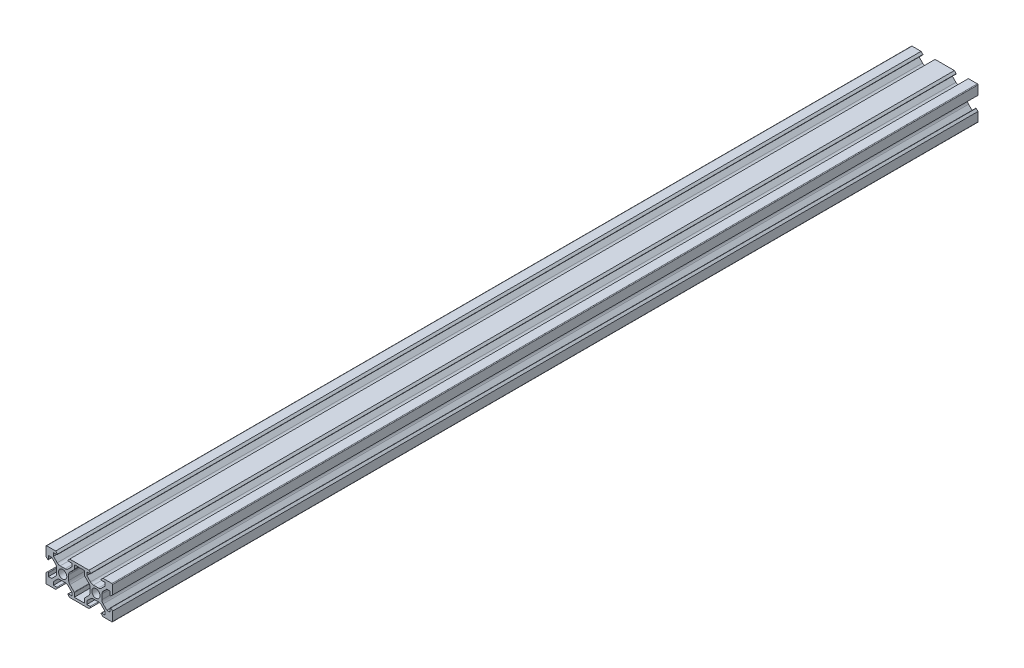
from build123d import *

# Parameters (mm, degrees)
RESSALTO_EXTRUS_O1_DEPTH = 260


with BuildPart() as part:
    # Esboço1 → Ressalto-extrusão1 (new body, symmetric)
    with BuildSketch(Plane.XY):
        with BuildLine():
            Line((-13.1, 8.9), (-14.2, 10))
            Line((-14.2, 10), (-19.6, 10))
            ThreePointArc((-19.6, 10), (-19.882842712, 9.882842712), (-20, 9.6))
            Line((-20, 9.6), (-20, 4.2))
            Line((-20, 4.2), (-18.9, 3.1))
            ThreePointArc((-18.9, 3.1), (-18.617157287, 3.217157287), (-18.5, 3.5))
            Line((-18.5, 3.5), (-18.5, 5.5))
            Line((-18.5, 5.5), (-16.560660172, 5.5))
            Line((-16.560660172, 5.5), (-14.332233047, 3.271572875))
            ThreePointArc((-14.332233047, 3.271572875), (-13.790301169, 2.460514503), (-13.6, 1.503805922))
            Line((-13.6, 1.503805922), (-13.6, 0))
            Line((-13.6, 0), (-13.6, -1.503805922))
            ThreePointArc((-13.6, -1.503805922), (-13.790301169, -2.460514503), (-14.332233047, -3.271572875))
            Line((-14.332233047, -3.271572875), (-16.560660172, -5.5))
            Line((-16.560660172, -5.5), (-18.5, -5.5))
            Line((-18.5, -5.5), (-18.5, -3.5))
            ThreePointArc((-18.5, -3.5), (-18.617157287, -3.217157288), (-18.9, -3.1))
            Line((-18.9, -3.1), (-20, -4.2))
            Line((-20, -4.2), (-20, -9.6))
            ThreePointArc((-20, -9.6), (-19.882842712, -9.882842712), (-19.6, -10))
            Line((-19.6, -10), (-14.2, -10))
            Line((-14.2, -10), (-13.1, -8.9))
            ThreePointArc((-13.1, -8.9), (-13.217157287, -8.617157288), (-13.5, -8.5))
            Line((-13.5, -8.5), (-15.5, -8.5))
            Line((-15.5, -8.5), (-15.5, -6.560660172))
            Line((-15.5, -6.560660172), (-13.271572875, -4.332233047))
            ThreePointArc((-13.271572875, -4.332233047), (-12.460514503, -3.790301169), (-11.503805922, -3.6))
            Line((-11.503805922, -3.6), (-10, -3.6))
            Line((-10, -3.6), (-8.496194078, -3.6))
            ThreePointArc((-8.496194078, -3.6), (-7.539485497, -3.790301169), (-6.728427125, -4.332233047))
            Line((-6.728427125, -4.332233047), (-4.5, -6.560660172))
            Line((-4.5, -6.560660172), (-4.5, -8.5))
            Line((-4.5, -8.5), (-6.5, -8.5))
            ThreePointArc((-6.5, -8.5), (-6.782842712, -8.617157288), (-6.9, -8.9))
            Line((-6.9, -8.9), (-5.8, -10))
            Line((-5.8, -10), (5.8, -10))
            Line((5.8, -10), (6.9, -8.9))
            ThreePointArc((6.9, -8.9), (6.782842712, -8.617157288), (6.5, -8.5))
            Line((6.5, -8.5), (4.5, -8.5))
            Line((4.5, -8.5), (4.5, -6.560660172))
            Line((4.5, -6.560660172), (6.728427125, -4.332233047))
            ThreePointArc((6.728427125, -4.332233047), (7.539485497, -3.790301169), (8.496194078, -3.6))
            Line((8.496194078, -3.6), (10, -3.6))
            Line((10, -3.6), (11.503805922, -3.6))
            ThreePointArc((11.503805922, -3.6), (12.460514503, -3.790301169), (13.271572875, -4.332233047))
            Line((13.271572875, -4.332233047), (15.5, -6.560660172))
            Line((15.5, -6.560660172), (15.5, -8.5))
            Line((15.5, -8.5), (13.5, -8.5))
            ThreePointArc((13.5, -8.5), (13.217157287, -8.617157288), (13.1, -8.9))
            Line((13.1, -8.9), (14.2, -10))
            Line((14.2, -10), (19.6, -10))
            ThreePointArc((19.6, -10), (19.882842712, -9.882842712), (20, -9.6))
            Line((20, -9.6), (20, -4.2))
            Line((20, -4.2), (18.9, -3.1))
            ThreePointArc((18.9, -3.1), (18.617157287, -3.217157288), (18.5, -3.5))
            Line((18.5, -3.5), (18.5, -5.5))
            Line((18.5, -5.5), (16.560660172, -5.5))
            Line((16.560660172, -5.5), (14.332233047, -3.271572875))
            ThreePointArc((14.332233047, -3.271572875), (13.790301169, -2.460514503), (13.6, -1.503805922))
            Line((13.6, -1.503805922), (13.6, 0))
            Line((13.6, 0), (13.6, 1.503805922))
            ThreePointArc((13.6, 1.503805922), (13.790301169, 2.460514503), (14.332233047, 3.271572875))
            Line((14.332233047, 3.271572875), (16.560660172, 5.5))
            Line((16.560660172, 5.5), (18.5, 5.5))
            Line((18.5, 5.5), (18.5, 3.5))
            ThreePointArc((18.5, 3.5), (18.617157287, 3.217157287), (18.9, 3.1))
            Line((18.9, 3.1), (20, 4.2))
            Line((20, 4.2), (20, 9.6))
            ThreePointArc((20, 9.6), (19.882842712, 9.882842712), (19.6, 10))
            Line((19.6, 10), (14.2, 10))
            Line((14.2, 10), (13.1, 8.9))
            ThreePointArc((13.1, 8.9), (13.217157287, 8.617157287), (13.5, 8.5))
            Line((13.5, 8.5), (15.5, 8.5))
            Line((15.5, 8.5), (15.5, 6.560660172))
            Line((15.5, 6.560660172), (13.271572875, 4.332233047))
            ThreePointArc((13.271572875, 4.332233047), (12.460514503, 3.790301169), (11.503805922, 3.6))
            Line((11.503805922, 3.6), (10, 3.6))
            Line((10, 3.6), (8.496194078, 3.6))
            ThreePointArc((8.496194078, 3.6), (7.539485497, 3.790301169), (6.728427125, 4.332233047))
            Line((6.728427125, 4.332233047), (4.5, 6.560660172))
            Line((4.5, 6.560660172), (4.5, 8.5))
            Line((4.5, 8.5), (6.5, 8.5))
            ThreePointArc((6.5, 8.5), (6.782842712, 8.617157288), (6.9, 8.9))
            Line((6.9, 8.9), (5.8, 10))
            Line((5.8, 10), (-5.8, 10))
            Line((-5.8, 10), (-6.9, 8.9))
            ThreePointArc((-6.9, 8.9), (-6.782842712, 8.617157288), (-6.5, 8.5))
            Line((-6.5, 8.5), (-4.5, 8.5))
            Line((-4.5, 8.5), (-4.5, 6.560660172))
            Line((-4.5, 6.560660172), (-6.728427125, 4.332233047))
            ThreePointArc((-6.728427125, 4.332233047), (-7.539485497, 3.790301169), (-8.496194078, 3.6))
            Line((-8.496194078, 3.6), (-10, 3.6))
            Line((-10, 3.6), (-11.503805922, 3.6))
            ThreePointArc((-11.503805922, 3.6), (-12.460514503, 3.790301169), (-13.271572875, 4.332233047))
            Line((-13.271572875, 4.332233047), (-15.5, 6.560660172))
            Line((-15.5, 6.560660172), (-15.5, 8.5))
            Line((-15.5, 8.5), (-13.5, 8.5))
            ThreePointArc((-13.5, 8.5), (-13.217157287, 8.617157287), (-13.1, 8.9))
        make_face()
        with BuildLine():
            Line((-3, 8.5), (3, 8.5))
            Line((3, 8.5), (3, 6.105025253))
            ThreePointArc((3, 6.105025253), (3.030448187, 5.95195188), (3.117157288, 5.822182541))
            Line((3.117157288, 5.822182541), (5.667766953, 3.271572875))
            ThreePointArc((5.667766953, 3.271572875), (6.209698831, 2.460514503), (6.4, 1.503805922))
            Line((6.4, 1.503805922), (6.4, 0))
            Line((6.4, 0), (6.4, -1.503805922))
            ThreePointArc((6.4, -1.503805922), (6.209698831, -2.460514503), (5.667766953, -3.271572875))
            Line((5.667766953, -3.271572875), (3.117157288, -5.822182541))
            ThreePointArc((3.117157288, -5.822182541), (3.030448187, -5.95195188), (3, -6.105025253))
            Line((3, -6.105025253), (3, -8.5))
            Line((3, -8.5), (-3, -8.5))
            Line((-3, -8.5), (-3, -6.105025253))
            ThreePointArc((-3, -6.105025253), (-3.030448187, -5.95195188), (-3.117157288, -5.822182541))
            Line((-3.117157288, -5.822182541), (-5.667766953, -3.271572875))
            ThreePointArc((-5.667766953, -3.271572875), (-6.209698831, -2.460514503), (-6.4, -1.503805922))
            Line((-6.4, -1.503805922), (-6.4, 0))
            Line((-6.4, 0), (-6.4, 1.503805922))
            ThreePointArc((-6.4, 1.503805922), (-6.209698831, 2.460514503), (-5.667766953, 3.271572875))
            Line((-5.667766953, 3.271572875), (-3.117157288, 5.822182541))
            ThreePointArc((-3.117157288, 5.822182541), (-3.030448187, 5.95195188), (-3, 6.105025253))
            Line((-3, 6.105025253), (-3, 8.5))
        make_face(mode=Mode.SUBTRACT)
        with BuildLine():
            ThreePointArc((-10, 2.5), (-11.767766953, 1.767766953), (-12.5, 0))
            ThreePointArc((-12.5, 0), (-11.767766953, -1.767766953), (-10, -2.5))
            ThreePointArc((-10, -2.5), (-8.232233047, -1.767766953), (-7.5, 0))
            ThreePointArc((-7.5, 0), (-8.232233047, 1.767766953), (-10, 2.5))
        make_face(mode=Mode.SUBTRACT)
        with BuildLine():
            ThreePointArc((12.5, 0), (11.767766953, -1.767766953), (10, -2.5))
            ThreePointArc((10, -2.5), (8.232233047, -1.767766953), (7.5, 0))
            ThreePointArc((7.5, 0), (8.232233047, 1.767766953), (10, 2.5))
            ThreePointArc((10, 2.5), (11.767766953, 1.767766953), (12.5, 0))
        make_face(mode=Mode.SUBTRACT)
    extrude(amount=RESSALTO_EXTRUS_O1_DEPTH, both=True)


solid = part.part
